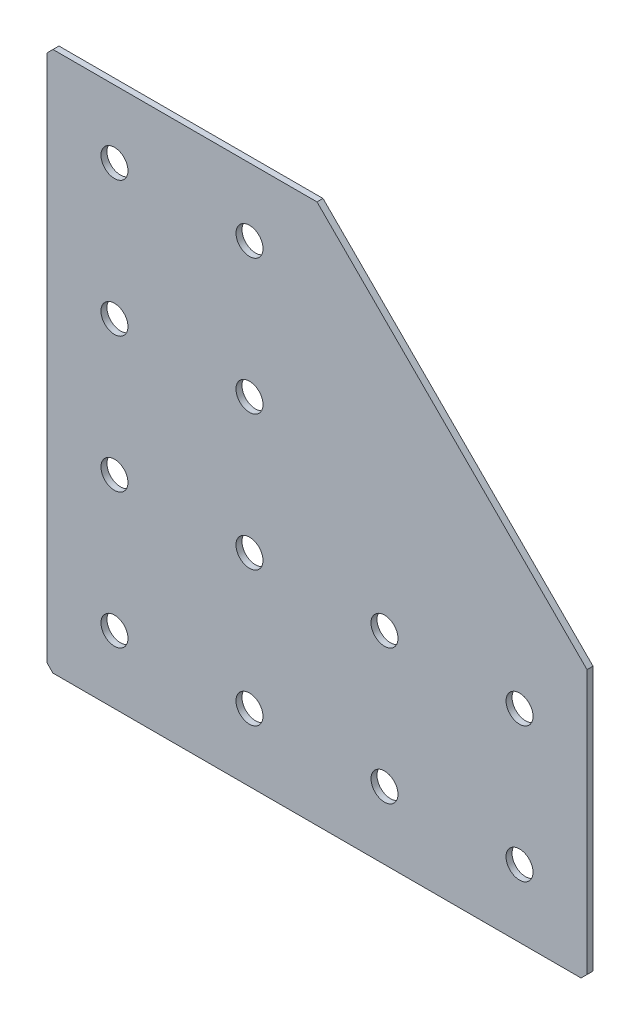
from build123d import *

# Parameters (mm, degrees)
EXTRUDE_1_DEPTH   = 2
HOLE_WIZARD_M81_D = 9
CHAMFER_1_SIZE    = 2


with BuildPart() as part:
    # Эскиз1 → Бобышка-Вытянуть1 (new body)
    with BuildSketch(Plane(origin=(0, 0, 0), x_dir=(1, 0, 0), z_dir=(0, 0, -1))):
        Polygon((0, 0), (0, 180), (180, 180), (180, 90), (90, 0), align=None)
    extrude(amount=EXTRUDE_1_DEPTH)

    # Отверстие с зазором M81 (through all)
    with Locations(Plane(origin=(0, 0, -2), x_dir=(1, 0, 0), z_dir=(0, 0, -1))):
        with Locations((22.5, 157.5), (22.5, 112.5), (22.5, 67.5), (22.5, 22.5), (67.5, 157.5), (67.5, 112.5), (67.5, 67.5), (67.5, 22.5), (112.5, 157.5), (112.5, 112.5), (157.5, 157.5), (157.5, 112.5)):
            Hole(HOLE_WIZARD_M81_D / 2)

    # Фаска1
    chamfer_1_edges = [part.edges().sort_by_distance(p)[0] for p in [
        (0, 0, -1),
        (0, -180, -1),
        (180, -180, -1),
    ]]
    chamfer(chamfer_1_edges, length=CHAMFER_1_SIZE)


solid = part.part
